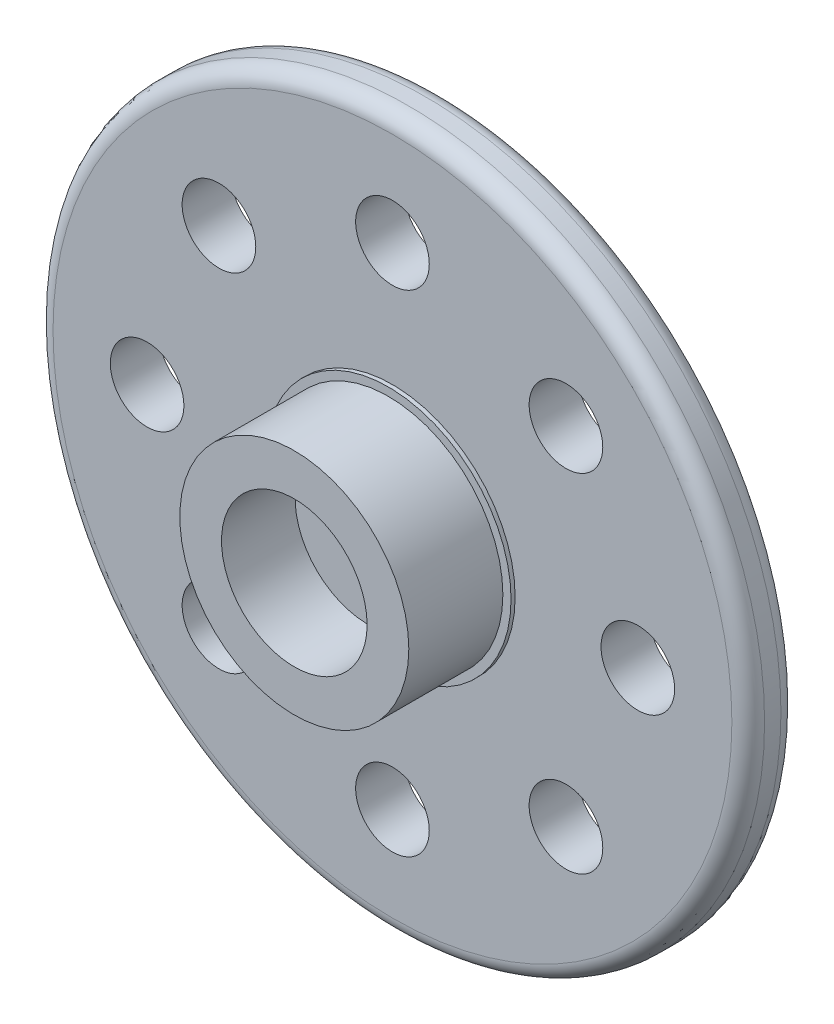
from build123d import *

# Parameters (mm, degrees)
SKETCH1_R           = 217.5
BOSS_EXTRUDE1_DEPTH = 30
SKETCH2_R           = 75
BOSS_EXTRUDE2_DEPTH = 2.5
SKETCH3_R           = 70
BOSS_EXTRUDE3_DEPTH = 57.5
SKETCH12_R          = 22.5
CUT_EXTRUDE2_DEPTH  = 30
FILLET2_R           = 10
SCALE2_SCALE        = 0.1
SKETCH14_R          = 4.45
CUT_EXTRUDE3_DEPTH  = 4.5


with BuildPart() as part:
    # Sketch1 → Boss-Extrude1 (new body)
    with BuildSketch(Plane.XY):
        Circle(SKETCH1_R)
    extrude(amount=BOSS_EXTRUDE1_DEPTH)

    # Sketch2 → Boss-Extrude2 (add)
    with BuildSketch(Plane.XY.offset(30)):
        Circle(SKETCH2_R)
    extrude(amount=BOSS_EXTRUDE2_DEPTH)

    # Sketch3 → Boss-Extrude3 (add)
    with BuildSketch(Plane.XY.offset(32.5)):
        Circle(SKETCH3_R)
    extrude(amount=BOSS_EXTRUDE3_DEPTH)

    # Sketch12 → Cut-Extrude2 (cut)
    with BuildSketch(Plane.XY.offset(30)):
        with Locations((0, 150)):
            Circle(SKETCH12_R)
        with Locations((106.066017178, 106.066017178)):
            Circle(SKETCH12_R)
        with Locations((150, 0)):
            Circle(SKETCH12_R)
        with Locations((106.066017178, -106.066017178)):
            Circle(SKETCH12_R)
        with Locations((0, -150)):
            Circle(SKETCH12_R)
        with Locations((-106.066017178, -106.066017178)):
            Circle(SKETCH12_R)
        with Locations((-150, 0)):
            Circle(SKETCH12_R)
        with Locations((-106.066017178, 106.066017178)):
            Circle(SKETCH12_R)
    extrude(amount=-CUT_EXTRUDE2_DEPTH, mode=Mode.SUBTRACT)

    # Fillet2
    fillet2_edges = [part.edges().sort_by_distance(p)[0] for p in [
        (-217.5, 0, 0),
        (-217.5, 0, 30),
    ]]
    fillet(fillet2_edges, radius=FILLET2_R)


with BuildPart() as part_1:
    # Scale2: scaled about (0, 0, 23.418586113)
    add(part.part.scale(SCALE2_SCALE).moved(Location((0, 0, 21.076727502))))

    # Sketch14 → Cut-Extrude3 (cut)
    with BuildSketch(Plane.XY.offset(30.076727502)):
        Circle(SKETCH14_R)
    extrude(amount=-CUT_EXTRUDE3_DEPTH, mode=Mode.SUBTRACT)


solid = part_1.part
